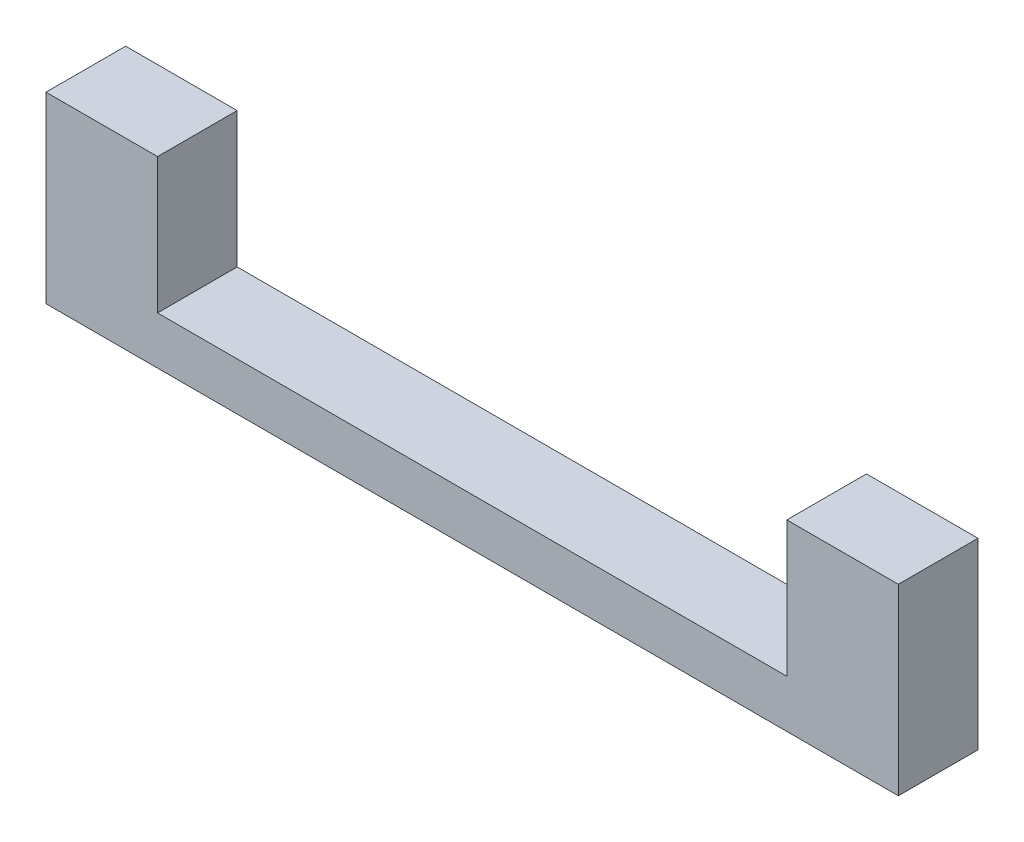
from build123d import *

# Parameters (mm, degrees)
SKETCH1_W           = 8.5
SKETCH1_H           = 8.5
BOSS_EXTRUDE1_DEPTH = 5
SKETCH2_W           = 8.5
SKETCH2_H           = 8.5
BOSS_EXTRUDE2_DEPTH = 2
SKETCH3_R           = 1.5
CUT_EXTRUDE1_DEPTH  = 2
SKETCH4_W           = 53.5
SKETCH4_H           = 8.5
BOSS_EXTRUDE3_DEPTH = 3
SKETCH5_W           = 7
SKETCH5_H           = 8.5
BOSS_EXTRUDE4_DEPTH = 8.5
SKETCH8_R           = 1.5
BOSS_EXTRUDE5_DEPTH = 2.5
SKETCH10_W          = 8.5
SKETCH10_H          = 8.5
BOSS_EXTRUDE7_DEPTH = 1
CUT_EXTRUDE4_DEPTH  = 0.5
SKETCH14_W          = 8.5
SKETCH14_H          = 8.5
BOSS_EXTRUDE8_DEPTH = 8
SKETCH15_W          = 8.5
SKETCH15_H          = 8.5
CUT_EXTRUDE6_DEPTH  = 1
SKETCH16_W          = 53.5
SKETCH16_H          = 3.5
CUT_EXTRUDE7_DEPTH  = 15
SKETCH17_W          = 5
SKETCH17_H          = 8.5
BOSS_EXTRUDE9_DEPTH = 7


with BuildPart() as part:
    # Sketch1 → Boss-Extrude1 (new body)
    with BuildSketch(Plane(origin=(0, 0, 0), x_dir=(0, 0, -1), z_dir=(1, 0, 0))):
        Rectangle(SKETCH1_W, SKETCH1_H)
        Polygon((1.705, 2.953146627), (-1.705, 2.953146627), (-3.41, 0), (-1.705, -2.953146627), (1.705, -2.953146627), (3.41, 0), align=None, mode=Mode.SUBTRACT)
    extrude(amount=BOSS_EXTRUDE1_DEPTH)

    # Sketch2 → Boss-Extrude2 (add)
    with BuildSketch(Plane.ZY):
        Rectangle(SKETCH2_W, SKETCH2_H)
    extrude(amount=BOSS_EXTRUDE2_DEPTH)

    # Sketch3 → Cut-Extrude1 (cut)
    with BuildSketch(Plane(origin=(0, 0, 0), x_dir=(0, 0, -1), z_dir=(1, 0, 0))):
        Circle(SKETCH3_R)
    extrude(amount=-CUT_EXTRUDE1_DEPTH, mode=Mode.SUBTRACT)

    # Sketch4 → Boss-Extrude3 (add)
    with BuildSketch(Plane.XZ.offset(4.25)):
        with Locations((24.75, 0)):
            Rectangle(SKETCH4_W, SKETCH4_H)
    extrude(amount=BOSS_EXTRUDE3_DEPTH)

    # Sketch5 → Boss-Extrude4 (add)
    with BuildSketch(Plane(origin=(0, -4.25, 0), x_dir=(1, 0, 0), z_dir=(0, 1, 0))):
        with Locations((48, 0)):
            Rectangle(SKETCH5_W, SKETCH5_H)
    extrude(amount=BOSS_EXTRUDE4_DEPTH)

    # Sketch8 → Boss-Extrude5 (add)
    with BuildSketch(Plane(origin=(0, 0, 0), x_dir=(0, 0, -1), z_dir=(1, 0, 0))):
        Polygon((-1.705, 2.953146627), (-3.41, 0), (-1.705, -2.953146627), (1.705, -2.953146627), (3.41, 0), (1.705, 2.953146627), align=None)
        Circle(SKETCH8_R, mode=Mode.SUBTRACT)
    extrude(amount=BOSS_EXTRUDE5_DEPTH)

    # Sketch10 → Boss-Extrude7 (add)
    with BuildSketch(Plane(origin=(5, 0, 0), x_dir=(0, 0, -1), z_dir=(1, 0, 0))):
        Rectangle(SKETCH10_W, SKETCH10_H)
        Polygon((3.41, 0), (1.705, 2.953146627), (-1.705, 2.953146627), (-3.41, 0), (-1.705, -2.953146627), (1.705, -2.953146627), align=None, mode=Mode.SUBTRACT)
    extrude(amount=BOSS_EXTRUDE7_DEPTH)

    # Sketch12 → Cut-Extrude4 (cut)
    with BuildSketch(Plane(origin=(2.5, 0, 0), x_dir=(0, 0, -1), z_dir=(1, 0, 0))):
        Polygon((1.705, -2.953146627), (3.41, 0), (1.705, 2.953146627), (-1.705, 2.953146627), (-3.41, 0), (-1.705, -2.953146627), align=None)
    extrude(amount=-CUT_EXTRUDE4_DEPTH, mode=Mode.SUBTRACT)

    # Sketch14 → Boss-Extrude8 (add)
    with BuildSketch(Plane(origin=(6, 0, 0), x_dir=(0, 0, -1), z_dir=(1, 0, 0))):
        Rectangle(SKETCH14_W, SKETCH14_H)
    extrude(amount=-BOSS_EXTRUDE8_DEPTH)

    # Sketch15 → Cut-Extrude6 (cut)
    with BuildSketch(Plane(origin=(6, 0, 0), x_dir=(0, 0, -1), z_dir=(1, 0, 0))):
        Rectangle(SKETCH15_W, SKETCH15_H)
    extrude(amount=-CUT_EXTRUDE6_DEPTH, mode=Mode.SUBTRACT)

    # Sketch16 → Cut-Extrude7 (cut)
    with BuildSketch(Plane(origin=(0, 4.25, 0), x_dir=(1, 0, 0), z_dir=(0, 1, 0))):
        with Locations((24.75, 2.5)):
            Rectangle(SKETCH16_W, SKETCH16_H)
    extrude(amount=-CUT_EXTRUDE7_DEPTH, mode=Mode.SUBTRACT)

    # Sketch17 → Boss-Extrude9 (add)
    with BuildSketch(Plane.ZY.offset(-44.5)):
        with Locations((1.75, 0)):
            Rectangle(SKETCH17_W, SKETCH17_H)
    extrude(amount=-BOSS_EXTRUDE9_DEPTH)


solid = part.part
